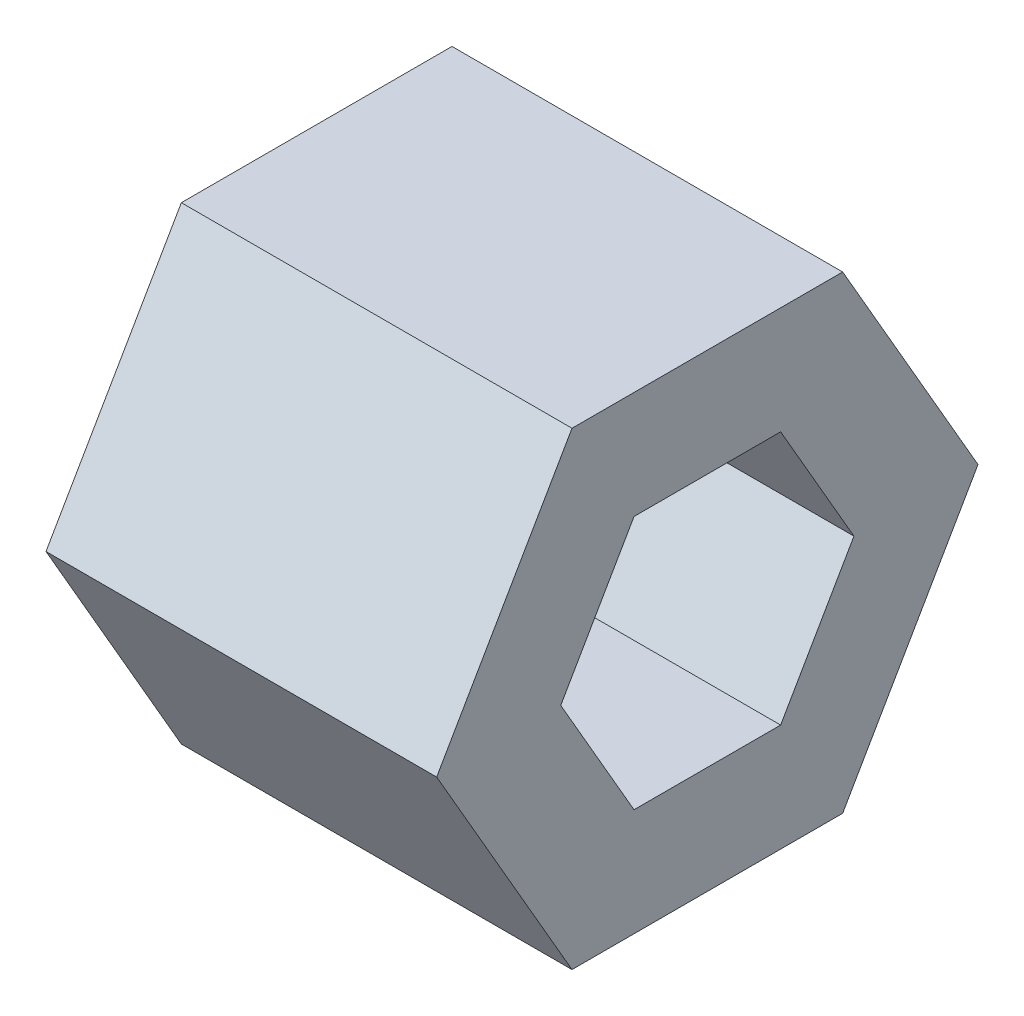
from build123d import *

# Parameters (mm, degrees)
EXTRUDE_1_DEPTH     = 10
CUT_EXTRUDE_1_DEPTH = 7
SKETCH_3_R          = 1.5
CUT_EXTRUDE_2_DEPTH = 7


with BuildPart() as part:
    # 草图1 → 凸台-拉伸1 (new body)
    with BuildSketch(Plane(origin=(0, 0, 0), x_dir=(0, 0, -1), z_dir=(1, 0, 0))):
        Polygon((6.92820323, 0), (3.464101615, 6), (-3.464101615, 6), (-6.92820323, 0), (-3.464101615, -6), (3.464101615, -6), align=None)
    extrude(amount=EXTRUDE_1_DEPTH)

    # 草图2 → 切除-拉伸1 (cut)
    with BuildSketch(Plane(origin=(10, 0, 0), x_dir=(0, 0, -1), z_dir=(1, 0, 0))):
        Polygon((3.75277675, 0), (1.876388375, 3.25), (-1.876388375, 3.25), (-3.75277675, 0), (-1.876388375, -3.25), (1.876388375, -3.25), align=None)
    extrude(amount=-CUT_EXTRUDE_1_DEPTH, mode=Mode.SUBTRACT)

    # 草图3 → 切除-拉伸2 (cut)
    with BuildSketch(Plane(origin=(3, 0, 0), x_dir=(0, 0, -1), z_dir=(1, 0, 0))):
        Circle(SKETCH_3_R)
    extrude(amount=-CUT_EXTRUDE_2_DEPTH, mode=Mode.SUBTRACT)


solid = part.part
